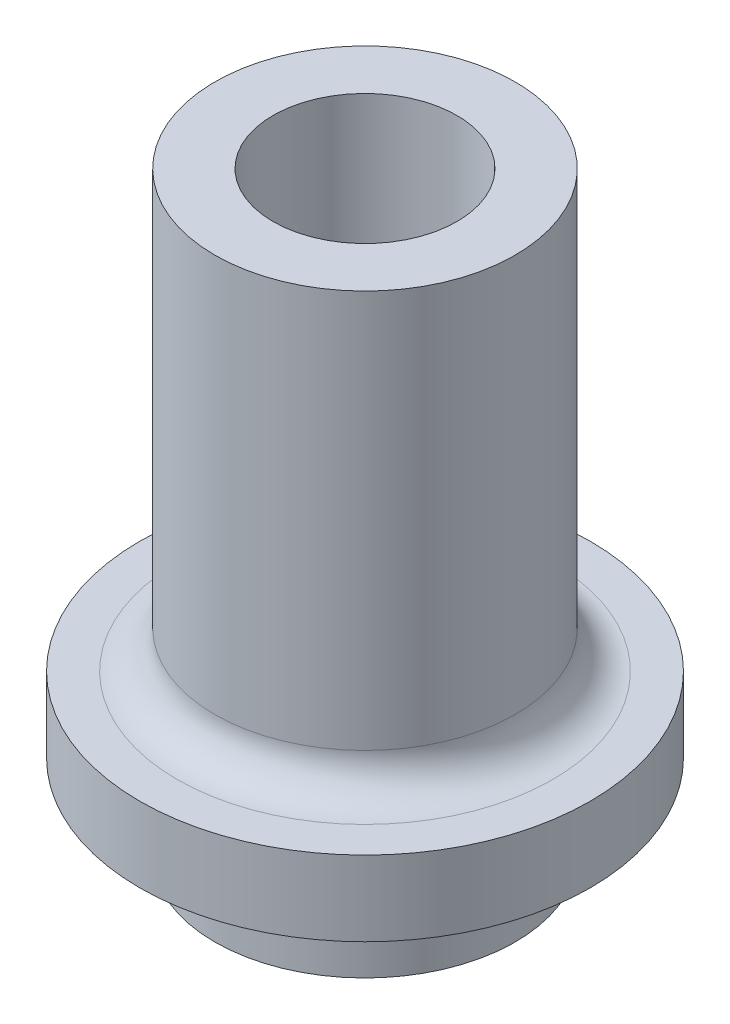
from build123d import *

# Parameters (mm, degrees)
SKETCH1_R           = 4
BOSS_EXTRUDE1_DEPTH = 9.25
SKETCH2_R           = 4
BOSS_EXTRUDE2_DEPTH = 1
SKETCH3_R           = 4
SKETCH3_R_2         = 2.45
BOSS_EXTRUDE3_DEPTH = 5.6
SKETCH5_R           = 6
BOSS_EXTRUDE4_DEPTH = 2
FILLET1_R           = 1


with BuildPart() as part:
    # Sketch1 → Boss-Extrude1 (new body)
    with BuildSketch(Plane(origin=(0, 0, 0), x_dir=(1, 0, 0), z_dir=(0, 1, 0))):
        Circle(SKETCH1_R)
        with BuildLine():
            Line((-1.12, 1.170469991), (1.12, 1.170469991))
            ThreePointArc((1.12, 1.170469991), (0, -1.62), (-1.12, 1.170469991))
        make_face(mode=Mode.SUBTRACT)
    extrude(amount=BOSS_EXTRUDE1_DEPTH)

    # Sketch2 → Boss-Extrude2 (add)
    with BuildSketch(Plane(origin=(0, 9.25, 0), x_dir=(1, 0, 0), z_dir=(0, 1, 0))):
        Circle(SKETCH2_R)
    extrude(amount=BOSS_EXTRUDE2_DEPTH)

    # Sketch3 → Boss-Extrude3 (add)
    with BuildSketch(Plane(origin=(0, 10.25, 0), x_dir=(1, 0, 0), z_dir=(0, 1, 0))):
        Circle(SKETCH3_R)
        Circle(SKETCH3_R_2, mode=Mode.SUBTRACT)
    extrude(amount=BOSS_EXTRUDE3_DEPTH)

    # Sketch5 → Boss-Extrude4 (add)
    with BuildSketch(Plane(origin=(0, 2.25, 0), x_dir=(1, 0, 0), z_dir=(0, 1, 0))):
        Circle(SKETCH5_R)
        with BuildLine():
            Line((1.12, 1.170469991), (-1.12, 1.170469991))
            ThreePointArc((-1.12, 1.170469991), (0, -1.62), (1.12, 1.170469991))
        make_face(mode=Mode.SUBTRACT)
    extrude(amount=BOSS_EXTRUDE4_DEPTH)

    # Fillet1
    fillet1_edges = [part.edges().sort_by_distance(p)[0] for p in [
        (-4, 4.25, 0),
    ]]
    fillet(fillet1_edges, radius=FILLET1_R)


solid = part.part
